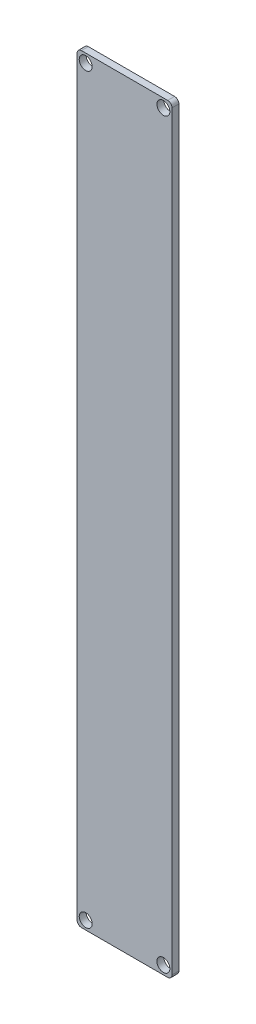
from build123d import *

# Parameters (mm, degrees)
SKETCH1_W           = 22
SKETCH1_H           = 176
BOSS_EXTRUDE1_DEPTH = 1.6
SKETCH2_R           = 1.5
CUT_EXTRUDE1_DEPTH  = 2.6
FILLET1_R           = 1


with BuildPart() as part:
    # Sketch1 → Boss-Extrude1 (new body)
    with BuildSketch(Plane.XY):
        with Locations((-24.538461538, -8.630769231)):
            Rectangle(SKETCH1_W, SKETCH1_H)
    extrude(amount=BOSS_EXTRUDE1_DEPTH)

    # Sketch2 → Cut-Extrude1 (cut, through all)
    with BuildSketch(Plane.XY.offset(1.6)):
        with Locations((-33.538461538, 77.369230769)):
            Circle(SKETCH2_R)
        with Locations((-15.538461538, 77.369230769)):
            Circle(SKETCH2_R)
        with Locations((-33.538461538, -94.630769231)):
            Circle(SKETCH2_R)
        with Locations((-15.538461538, -94.630769231)):
            Circle(SKETCH2_R)
    extrude(amount=-CUT_EXTRUDE1_DEPTH, mode=Mode.SUBTRACT)

    # Fillet1
    fillet1_edges = [part.edges().sort_by_distance(p)[0] for p in [
        (-35.538461538, 79.369230769, 0.8),
        (-13.538461538, 79.369230769, 0.8),
        (-13.538461538, -96.630769231, 0.8),
        (-35.538461538, -96.630769231, 0.8),
    ]]
    fillet(fillet1_edges, radius=FILLET1_R)


solid = part.part
